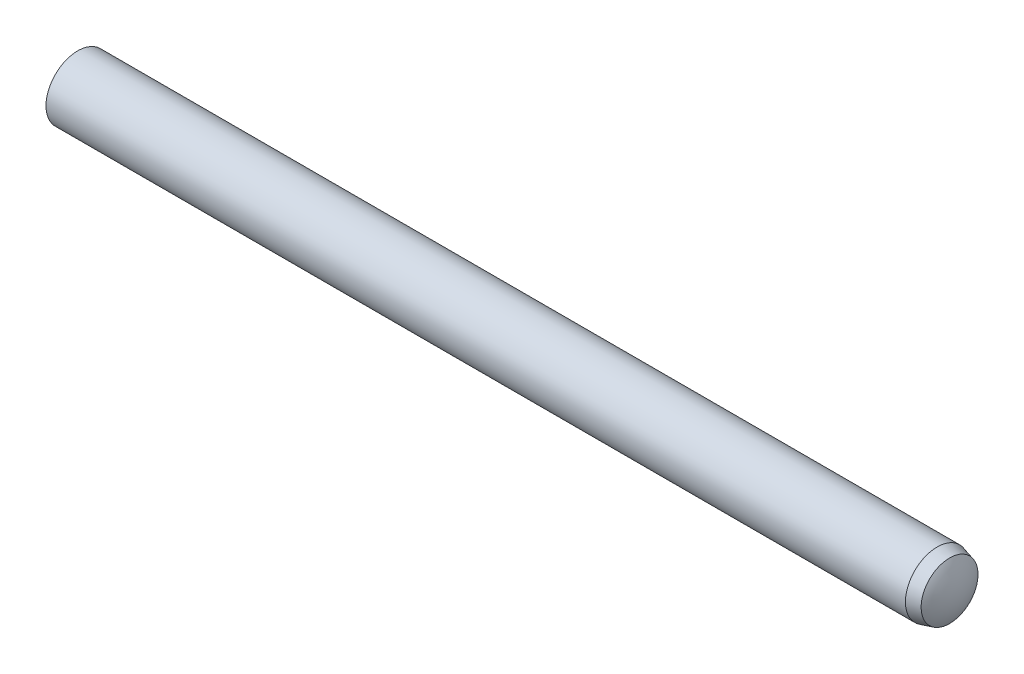
from build123d import *

# Parameters (mm, degrees)
SKETCH2_R           = 2.5
EXTRUDE1_DEPTH      = 35
EXTRUDE1_DEPTH_BACK = 35


with BuildPart() as part:
    # Sketch2 → Extrude1 (new body, two sides)
    with BuildSketch(Plane(origin=(0, 0, 0), x_dir=(0, 0, -1), z_dir=(1, 0, 0))) as extrude1_sk:
        Circle(SKETCH2_R)
    extrude(amount=EXTRUDE1_DEPTH)
    extrude(extrude1_sk.sketch, amount=-EXTRUDE1_DEPTH_BACK)

    # Sketch5 → Cut-Revolve1 (revolve, cut)
    with BuildSketch(Plane.XY):
        with BuildLine():
            Line((33.375, 2.5), (33.375, 3))
            Line((33.375, 3), (35.5, 3))
            Line((35.5, 3), (35.5, 0))
            Line((35.5, 0), (35, 0))
            ThreePointArc((35, 0), (34.834212566, 1.165600649), (34.35, 2.238749537))
            Line((34.35, 2.238749537), (33.375, 2.5))
        make_face()
        with BuildLine():
            Line((-34.25, 2.5), (-34.25, 3))
            Line((-34.25, 3), (-35.5, 3))
            Line((-35.5, 3), (-35.5, 0))
            Line((-35.5, 0), (-35, 0))
            ThreePointArc((-35, 0), (-34.808461045, 1.305038314), (-34.25, 2.5))
        make_face()
    revolve(axis=Axis((-35, 0, 0), (1, 0, 0)), mode=Mode.SUBTRACT)


solid = part.part
